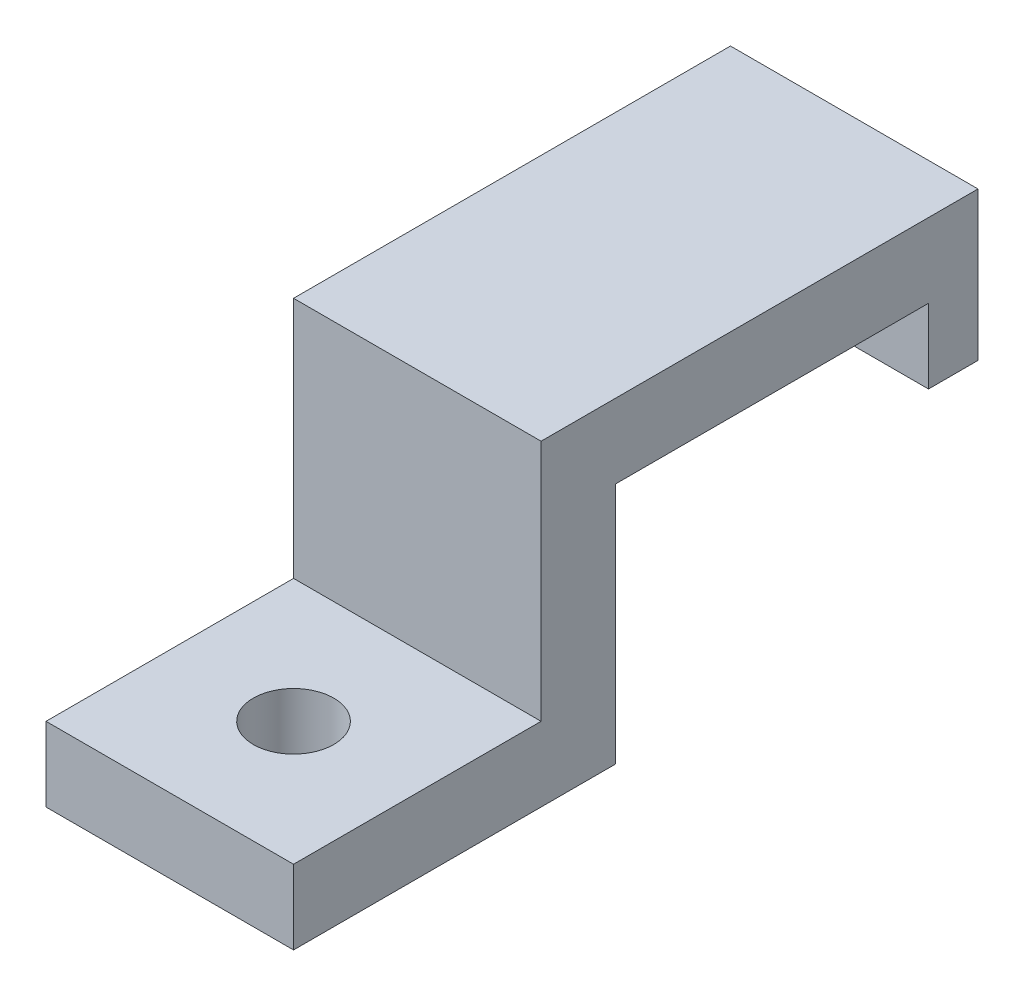
from build123d import *

# Parameters (mm, degrees)
SALIENTE_EXTRUIR1_DEPTH = 10
CROQUIS4_W              = 2
CROQUIS4_H              = 6
SALIENTE_EXTRUIR2_DEPTH = 10
CROQUIS5_R              = 1.625
CORTAR_EXTRUIR1_DEPTH   = 4


with BuildPart() as part:
    # Croquis2 → Saliente-Extruir1 (new body)
    with BuildSketch(Plane(origin=(0, 0, 0), x_dir=(0, 0, -1), z_dir=(1, 0, 0))):
        Polygon((0, 0), (13, 0), (13, 9.8), (25.65, 9.8), (25.65, 12.8), (10, 12.8), (10, 3), (0, 3), align=None)
    extrude(amount=SALIENTE_EXTRUIR1_DEPTH)

    # Croquis4 → Saliente-Extruir2 (add, through all)
    with BuildSketch(Plane(origin=(0, 0, 0), x_dir=(0, 0, -1), z_dir=(1, 0, 0))):
        with Locations((26.65, 9.8)):
            Rectangle(CROQUIS4_W, CROQUIS4_H)
    extrude(amount=SALIENTE_EXTRUIR2_DEPTH)

    # Croquis5 → Cortar-Extruir1 (cut, through all)
    with BuildSketch(Plane(origin=(0, 3, 0), x_dir=(1, 0, 0), z_dir=(0, 1, 0))):
        with Locations((5, 5)):
            Circle(CROQUIS5_R)
    extrude(amount=-CORTAR_EXTRUIR1_DEPTH, mode=Mode.SUBTRACT)


solid = part.part
